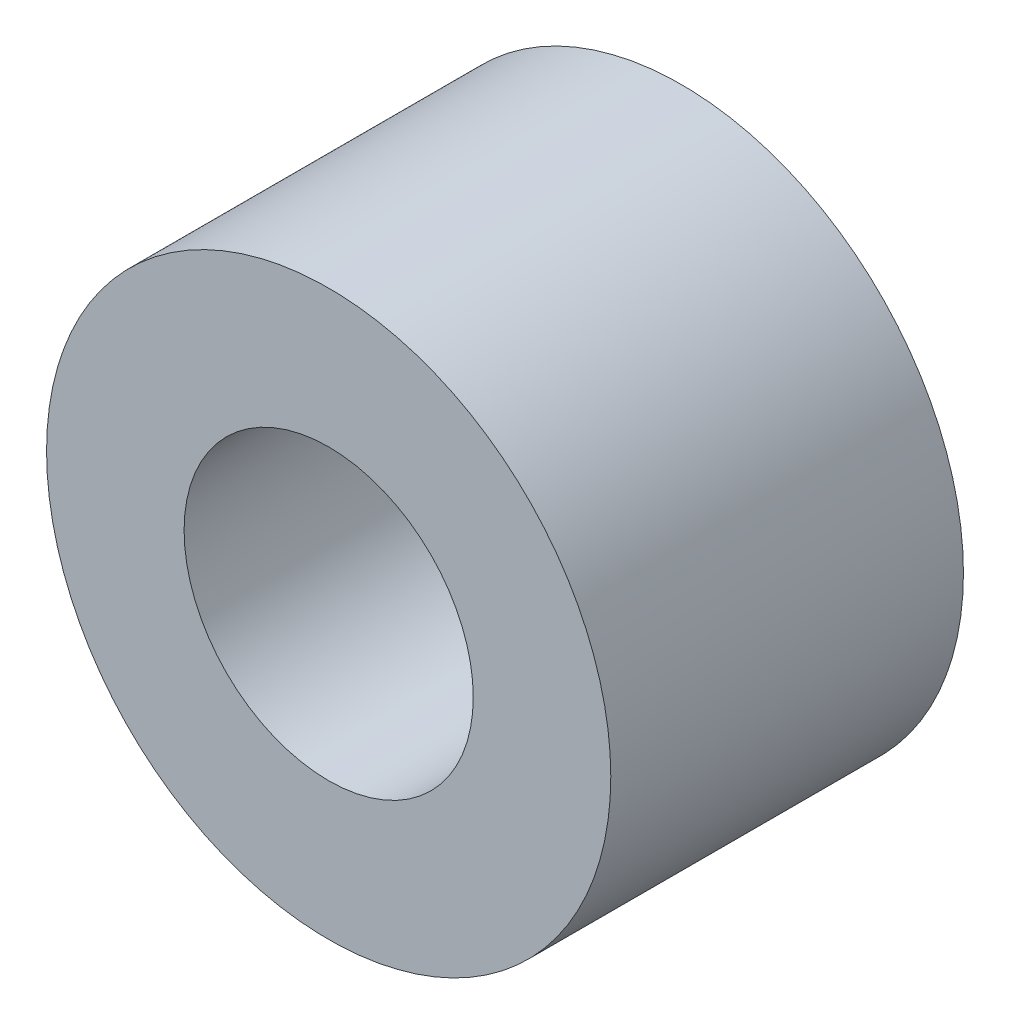
from build123d import *

# Parameters (mm, degrees)
SKETCH1_R           = 8
SKETCH1_R_2         = 4.1
BOSS_EXTRUDE1_DEPTH = 10


with BuildPart() as part:
    # Sketch1 → Boss-Extrude1 (new body)
    with BuildSketch(Plane.XY):
        Circle(SKETCH1_R)
        Circle(SKETCH1_R_2, mode=Mode.SUBTRACT)
    extrude(amount=BOSS_EXTRUDE1_DEPTH)


solid = part.part
